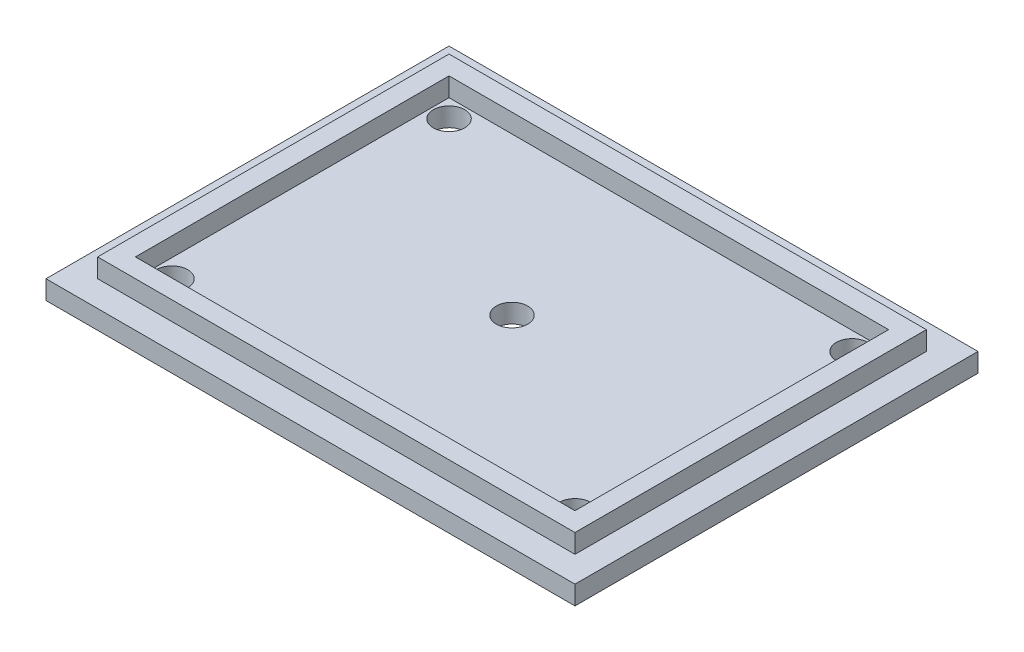
from build123d import *

# Parameters (mm, degrees)
CROQUIS1_W              = 84
CROQUIS1_H              = 64
SALIENTE_EXTRUIR1_DEPTH = 3
CROQUIS2_W              = 75.8
CROQUIS2_H              = 55.8
CROQUIS2_W_2            = 69.8
CROQUIS2_H_2            = 49.8
SALIENTE_EXTRUIR2_DEPTH = 3
CROQUIS3_R              = 2.5
CORTAR_EXTRUIR1_DEPTH   = 7


with BuildPart() as part:
    # Croquis1 → Saliente-Extruir1 (new body)
    with BuildSketch(Plane(origin=(0, 0, 0), x_dir=(1, 0, 0), z_dir=(0, 1, 0))):
        with Locations((42, 32)):
            Rectangle(CROQUIS1_W, CROQUIS1_H)
    extrude(amount=SALIENTE_EXTRUIR1_DEPTH)

    # Croquis2 → Saliente-Extruir2 (add)
    with BuildSketch(Plane(origin=(0, 3, 0), x_dir=(1, 0, 0), z_dir=(0, 1, 0))):
        with Locations((42, 32)):
            Rectangle(CROQUIS2_W, CROQUIS2_H)
        with Locations((42, 32)):
            Rectangle(CROQUIS2_W_2, CROQUIS2_H_2, mode=Mode.SUBTRACT)
    extrude(amount=SALIENTE_EXTRUIR2_DEPTH)

    # Croquis3 → Cortar-Extruir1 (cut, through all)
    with BuildSketch(Plane.XZ):
        with Locations((42, -32)):
            Circle(CROQUIS3_R)
        with Locations((10, -10)):
            Circle(CROQUIS3_R)
        with Locations((74, -10)):
            Circle(CROQUIS3_R)
        with Locations((74, -54)):
            Circle(CROQUIS3_R)
        with Locations((10, -54)):
            Circle(CROQUIS3_R)
    extrude(amount=-CORTAR_EXTRUIR1_DEPTH, mode=Mode.SUBTRACT)


solid = part.part
